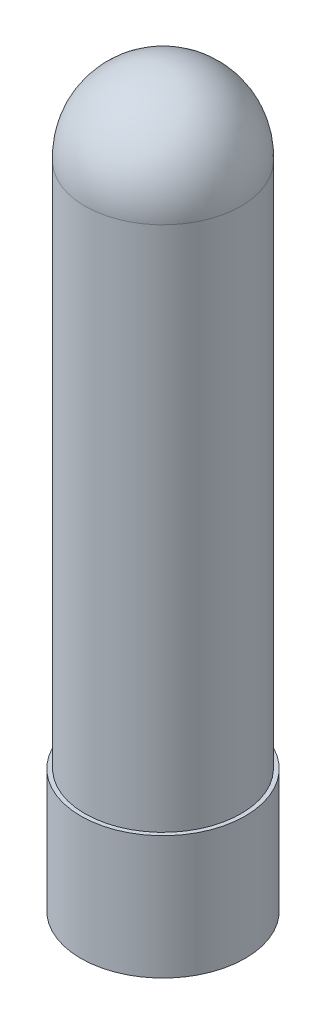
from build123d import *

# Parameters (mm, degrees)
SKETCH1_R           = 10
BOSS_EXTRUDE1_DEPTH = 15
BOSS_EXTRUDE3_START = -15
SKETCH3_R           = 9.5
BOSS_EXTRUDE3_DEPTH = 64
DOME1_FACE_RADIUS   = 9.5
DOME1_HEIGHT        = 10


with BuildPart() as part:
    # Sketch1 → Boss-Extrude1 (new body)
    with BuildSketch(Plane(origin=(0, 0, 0), x_dir=(1, 0, 0), z_dir=(0, 1, 0))):
        Circle(SKETCH1_R)
    extrude(amount=BOSS_EXTRUDE1_DEPTH)

    # Sketch3 → Boss-Extrude3 (add)
    with BuildSketch(Plane.XZ.offset(BOSS_EXTRUDE3_START)):
        Circle(SKETCH3_R)
    extrude(amount=-BOSS_EXTRUDE3_DEPTH)

    # Dome1: a dome of height H over a round flat face of radius A is a cap of a sphere of radius (A * A + H * H) / (2 * H)
    dome1_r = (DOME1_FACE_RADIUS * DOME1_FACE_RADIUS + DOME1_HEIGHT * DOME1_HEIGHT) / (2 * DOME1_HEIGHT)
    dome1_base = Plane((0, 79, 0), z_dir=(0, 1, 0))
    with Locations(dome1_base.offset(DOME1_HEIGHT - dome1_r)):
        dome1_ball = Sphere(dome1_r, mode=Mode.PRIVATE)
    add(split(dome1_ball, bisect_by=dome1_base, keep=Keep.TOP, mode=Mode.PRIVATE))


solid = part.part
